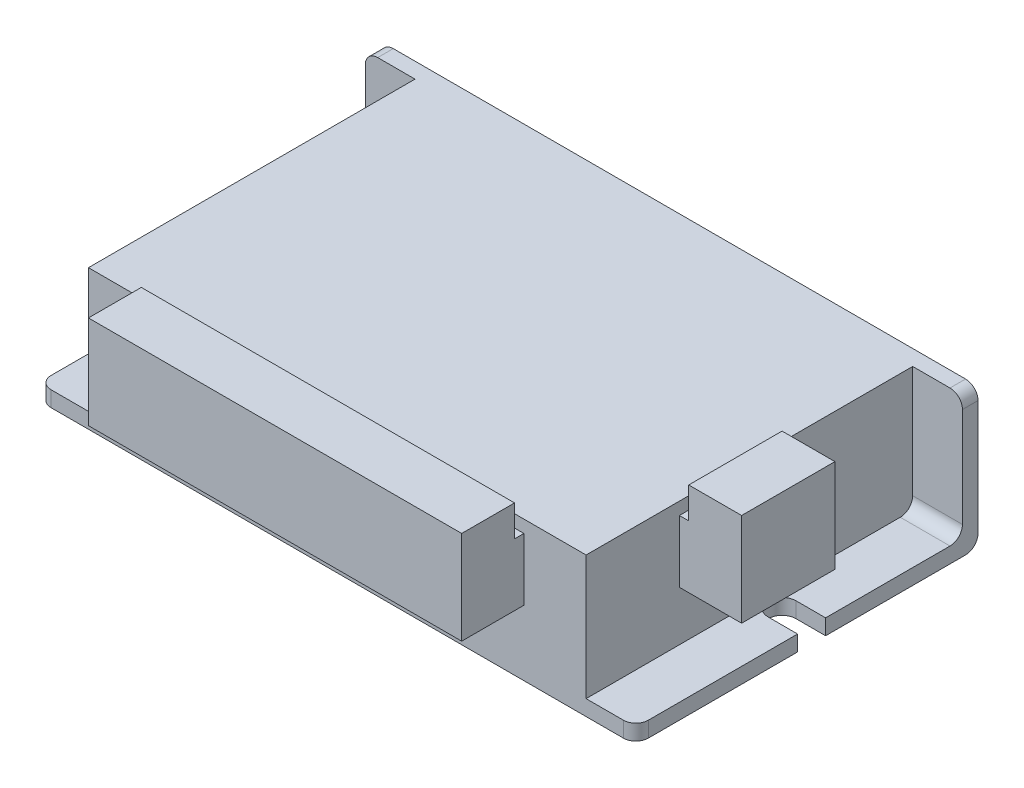
from build123d import *

# Parameters (mm, degrees)
SKETCH_1_W          = 80
SKETCH_1_H          = 55
EXTRUDE_1_DEPTH     = 20
SKETCH_2_W          = 15
SKETCH_2_H          = 10
EXTRUDE_2_DEPTH     = 10
SKETCH_3_W          = 8.5
SKETCH_3_H          = 15
EXTRUDE_3_DEPTH     = 5
SKETCH_4_W          = 60
SKETCH_4_H          = 10
EXTRUDE_4_DEPTH     = 10
SKETCH_5_W          = 60
SKETCH_5_H          = 8.5
EXTRUDE_5_DEPTH     = 5
SKETCH_6_W          = 96
SKETCH_6_H          = 20
EXTRUDE_6_DEPTH     = 2.5
SKETCH_7_W          = 96
SKETCH_7_H          = 55
EXTRUDE_8_DEPTH     = 2.5
FILLET_1_R          = 2
CUT_EXTRUDE_1_DEPTH = 2.5


with BuildPart() as part:
    # 草图1 → 凸台-拉伸1 (new body)
    with BuildSketch(Plane(origin=(0, 0, 0), x_dir=(1, 0, 0), z_dir=(0, 1, 0))):
        Rectangle(SKETCH_1_W, SKETCH_1_H)
    extrude(amount=EXTRUDE_1_DEPTH)

    # 草图2 → 凸台-拉伸2 (add)
    with BuildSketch(Plane(origin=(40, 0, 0), x_dir=(0, 0, -1), z_dir=(1, 0, 0))):
        with Locations((-5, 13)):
            Rectangle(SKETCH_2_W, SKETCH_2_H)
    extrude(amount=EXTRUDE_2_DEPTH)

    # 草图3 → 凸台-拉伸3 (add)
    with BuildSketch(Plane(origin=(0, 18, 0), x_dir=(1, 0, 0), z_dir=(0, 1, 0))):
        with Locations((45.75, -5)):
            Rectangle(SKETCH_3_W, SKETCH_3_H)
    extrude(amount=EXTRUDE_3_DEPTH)

    # 草图4 → 凸台-拉伸4 (add)
    with BuildSketch(Plane.XY.offset(27.5)):
        with Locations((0, 13)):
            Rectangle(SKETCH_4_W, SKETCH_4_H)
    extrude(amount=EXTRUDE_4_DEPTH)

    # 草图5 → 凸台-拉伸5 (add)
    with BuildSketch(Plane(origin=(0, 18, 0), x_dir=(1, 0, 0), z_dir=(0, 1, 0))):
        with Locations((0, -33.25)):
            Rectangle(SKETCH_5_W, SKETCH_5_H)
    extrude(amount=EXTRUDE_5_DEPTH)

    # 草图6 → 凸台-拉伸6 (add)
    with BuildSketch(Plane(origin=(0, 0, -27.5), x_dir=(-1, 0, 0), z_dir=(0, 0, -1))):
        with Locations((0, 10)):
            Rectangle(SKETCH_6_W, SKETCH_6_H)
    extrude(amount=-EXTRUDE_6_DEPTH)

    # 草图7 → 凸台-拉伸8 (add)
    with BuildSketch(Plane.XZ):
        Rectangle(SKETCH_7_W, SKETCH_7_H)
    extrude(amount=EXTRUDE_8_DEPTH)

    # 圆角1
    fillet_1_edges = [part.edges().sort_by_distance(p)[0] for p in [
        (48, 20, -26.25),
        (44, 0, -25),
        (-44, 0, -25),
        (-48, 20, -26.25),
        (-48, -1.25, 27.5),
        (48, -1.25, 27.5),
        (0, -2.5, -27.5),
    ]]
    fillet(fillet_1_edges, radius=FILLET_1_R)

    # 草图8 → 切除-拉伸1 (cut)
    with BuildSketch(Plane.XZ.offset(2.5)):
        with BuildLine():
            Line((-48, -3), (-43.25, -3))
            ThreePointArc((-43.25, -3), (-41, -0.75), (-43.25, 1.5))
            Line((-43.25, 1.5), (-48, 1.5))
            Line((-48, 1.5), (-48, -3))
        make_face()
        with BuildLine():
            Line((48, 1.5), (48, -3))
            Line((48, -3), (43.25, -3))
            ThreePointArc((43.25, -3), (41, -0.75), (43.25, 1.5))
            Line((43.25, 1.5), (48, 1.5))
        make_face()
    extrude(amount=-CUT_EXTRUDE_1_DEPTH, mode=Mode.SUBTRACT)


solid = part.part
